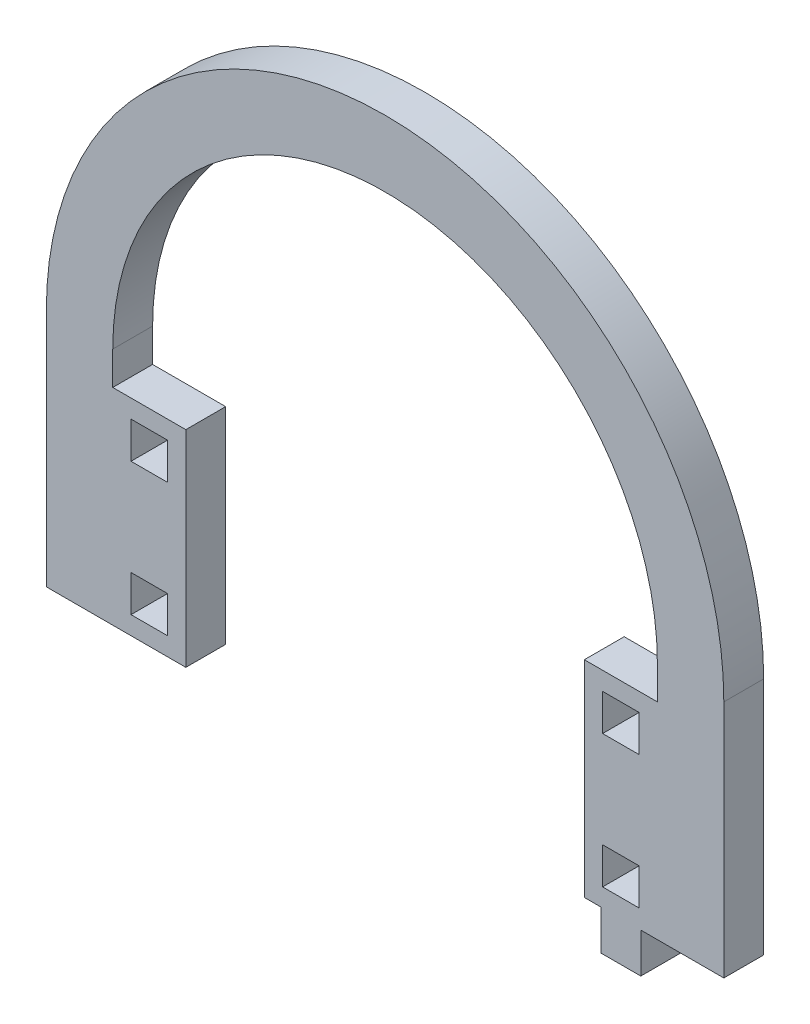
from build123d import *

# Parameters (mm, degrees)
MODEL_W             = 5.5
MODEL_H             = 5.5
BOSS_EXTRUDE1_DEPTH = 6


with BuildPart() as part:
    # Model → Boss-Extrude1 (new body)
    with BuildSketch(Plane.XY):
        with BuildLine():
            Line((3076.532777825, 1463.171342736), (3076.532777825, 1427.171342736))
            Line((3076.532777825, 1427.171342736), (3086.532777825, 1427.171342736))
            Line((3086.532777825, 1427.171342736), (3097.532777825, 1427.171342736))
            Line((3097.532777825, 1427.171342736), (3097.532777825, 1458.171342736))
            Line((3097.532777825, 1458.171342736), (3086.532777825, 1458.171342736))
            Line((3086.532777825, 1458.171342736), (3086.532777825, 1463.171342736))
            ThreePointArc((3086.532777825, 1463.171342736), (3127.532777825, 1504.171342736), (3168.532777825, 1463.171342736))
            Line((3168.532777825, 1463.171342736), (3168.532777825, 1458.171342736))
            Line((3168.532777825, 1458.171342736), (3157.532777825, 1458.171342736))
            Line((3157.532777825, 1458.171342736), (3157.532777825, 1427.171342736))
            Line((3157.532777825, 1427.171342736), (3160.032777825, 1427.171342736))
            Line((3160.032777825, 1427.171342736), (3160.032777825, 1421.171342736))
            Line((3160.032777825, 1421.171342736), (3166.032777825, 1421.171342736))
            Line((3166.032777825, 1421.171342736), (3166.032777825, 1427.171342736))
            Line((3166.032777825, 1427.171342736), (3178.532777825, 1427.171342736))
            Line((3178.532777825, 1427.171342736), (3178.532777825, 1463.171342736))
            ThreePointArc((3178.532777825, 1463.171342736), (3127.532777825, 1514.171342736), (3076.532777825, 1463.171342736))
        make_face()
        with Locations((3163.032777825, 1432.671342736)):
            Rectangle(MODEL_W, MODEL_H, mode=Mode.SUBTRACT)
        with Locations((3163.032777825, 1452.671342736)):
            Rectangle(MODEL_W, MODEL_H, mode=Mode.SUBTRACT)
        with Locations((3092.032777825, 1432.671342736)):
            Rectangle(MODEL_W, MODEL_H, mode=Mode.SUBTRACT)
        with Locations((3092.032777825, 1452.671342736)):
            Rectangle(MODEL_W, MODEL_H, mode=Mode.SUBTRACT)
    extrude(amount=BOSS_EXTRUDE1_DEPTH)


solid = part.part
